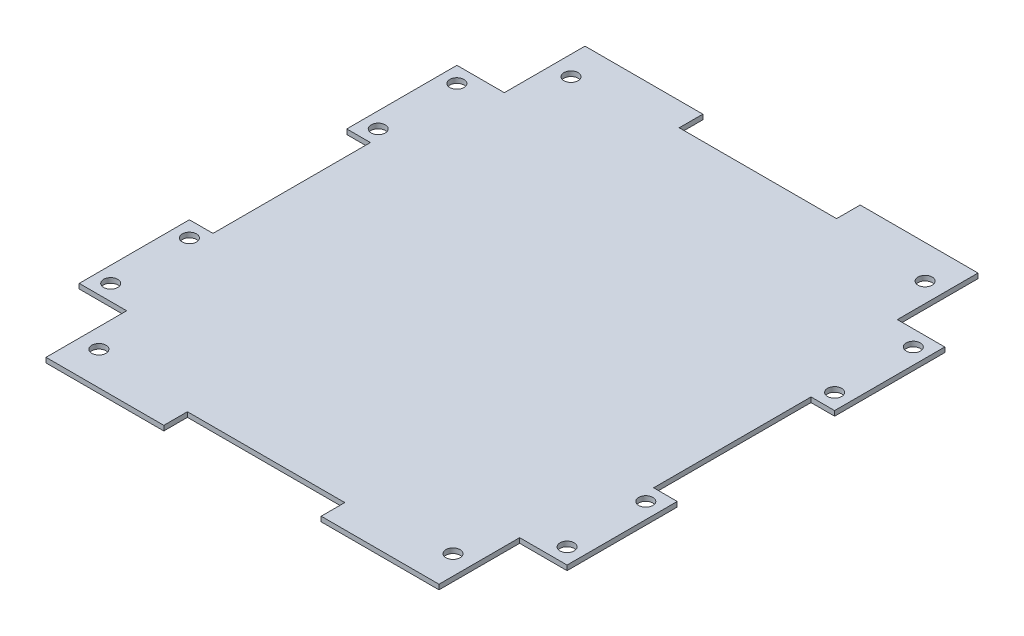
from build123d import *

# Parameters (mm, degrees)
SKETCH1_R           = 2.286
BOSS_EXTRUDE1_DEPTH = 1.5875
SKETCH2_R           = 2.286
CUT_EXTRUDE1_DEPTH  = 2.5875


with BuildPart() as part:
    # Sketch1 → Boss-Extrude1 (new body)
    with BuildSketch(Plane(origin=(0, 0, 0), x_dir=(1, 0, 0), z_dir=(0, 1, 0))):
        Polygon((-25.4, 86.995), (-63.43142, 86.995), (-63.43142, 60.96), (-78.74, 60.96), (-78.74, 25.4), (-71.12, 25.4), (-71.12, -25.4), (-78.74, -25.4), (-78.74, -60.96), (-63.43142, -60.96), (-63.43142, -86.995), (-25.4, -86.995), (-25.4, -79.375), (25.4, -79.375), (25.4, -86.995), (63.43142, -86.995), (63.43142, -60.96), (78.74, -60.96), (78.74, -25.4), (71.12, -25.4), (71.12, 25.4), (78.74, 25.4), (78.74, 60.96), (63.43142, 60.96), (63.43142, 86.995), (25.4, 86.995), (25.4, 79.375), (-25.4, 79.375), align=None)
        with Locations((-57.15, 76.2)):
            Circle(SKETCH1_R, mode=Mode.SUBTRACT)
        with Locations((57.15, 76.2)):
            Circle(SKETCH1_R, mode=Mode.SUBTRACT)
        with Locations((57.15, -76.2)):
            Circle(SKETCH1_R, mode=Mode.SUBTRACT)
        with Locations((-57.15, -76.2)):
            Circle(SKETCH1_R, mode=Mode.SUBTRACT)
    extrude(amount=BOSS_EXTRUDE1_DEPTH)

    # Sketch2 → Cut-Extrude1 (cut, through all)
    with BuildSketch(Plane(origin=(0, 1.5875, 0), x_dir=(1, 0, 0), z_dir=(0, 1, 0))):
        with Locations((-73.66, -30.48)):
            Circle(SKETCH2_R)
        with Locations((-73.66, -55.88)):
            Circle(SKETCH2_R)
        with Locations((73.66, -55.88)):
            Circle(SKETCH2_R)
        with Locations((73.66, -30.48)):
            Circle(SKETCH2_R)
        with Locations((73.66, 30.48)):
            Circle(SKETCH2_R)
        with Locations((73.66, 55.88)):
            Circle(SKETCH2_R)
        with Locations((-73.66, 55.88)):
            Circle(SKETCH2_R)
        with Locations((-73.66, 30.48)):
            Circle(SKETCH2_R)
    extrude(amount=-CUT_EXTRUDE1_DEPTH, mode=Mode.SUBTRACT)


solid = part.part
